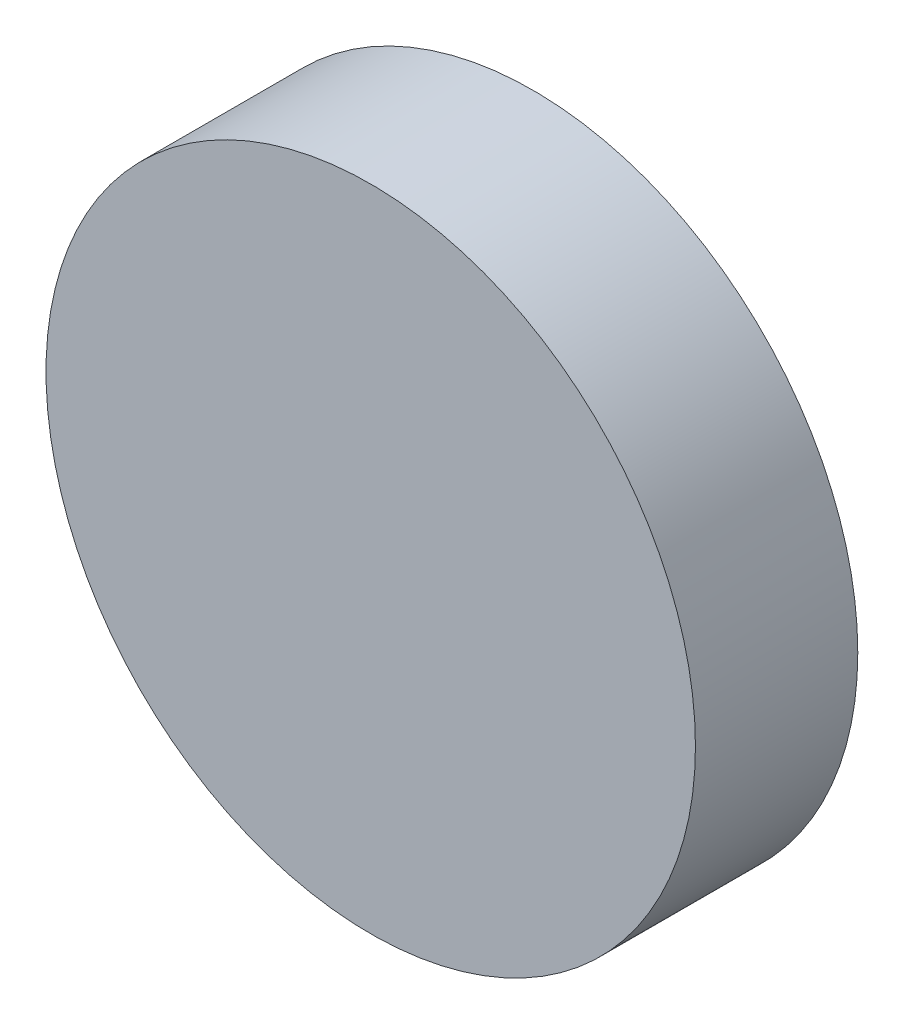
from build123d import *

# Parameters (mm, degrees)
SKETCH1_R           = 3.175
BOSS_EXTRUDE1_DEPTH = 1.5875


with BuildPart() as part:
    # Sketch1 → Boss-Extrude1 (new body)
    with BuildSketch(Plane.XY):
        Circle(SKETCH1_R)
    extrude(amount=BOSS_EXTRUDE1_DEPTH)


solid = part.part
